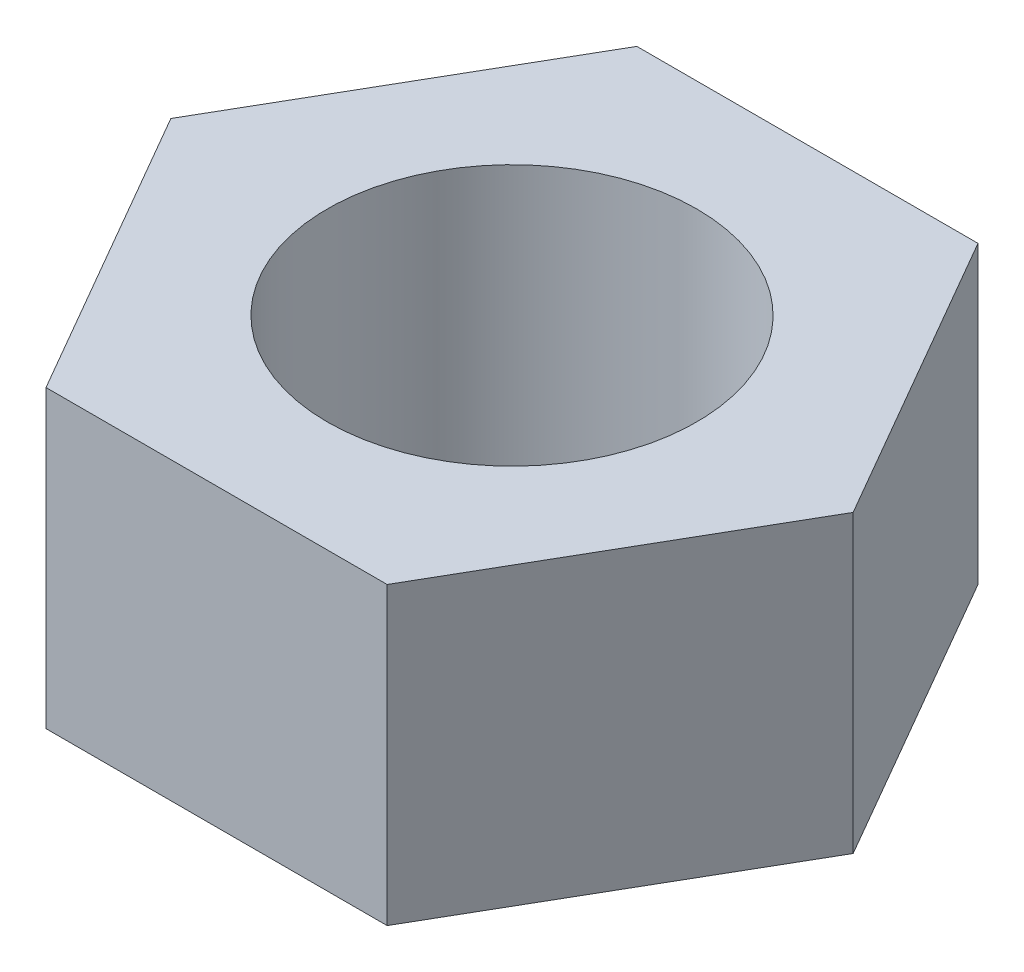
from build123d import *

# Parameters (mm, degrees)
SKETCH1_R           = 2.5
BOSS_EXTRUDE1_DEPTH = 4


with BuildPart() as part:
    # Sketch1 → Boss-Extrude1 (new body)
    with BuildSketch(Plane(origin=(0, 0, 0), x_dir=(1, 0, 0), z_dir=(0, 1, 0))):
        Polygon((-4.618802154, 0), (-2.309401077, -4), (2.309401077, -4), (4.618802154, 0), (2.309401077, 4), (-2.309401077, 4), align=None)
        Circle(SKETCH1_R, mode=Mode.SUBTRACT)
    extrude(amount=BOSS_EXTRUDE1_DEPTH)


solid = part.part
